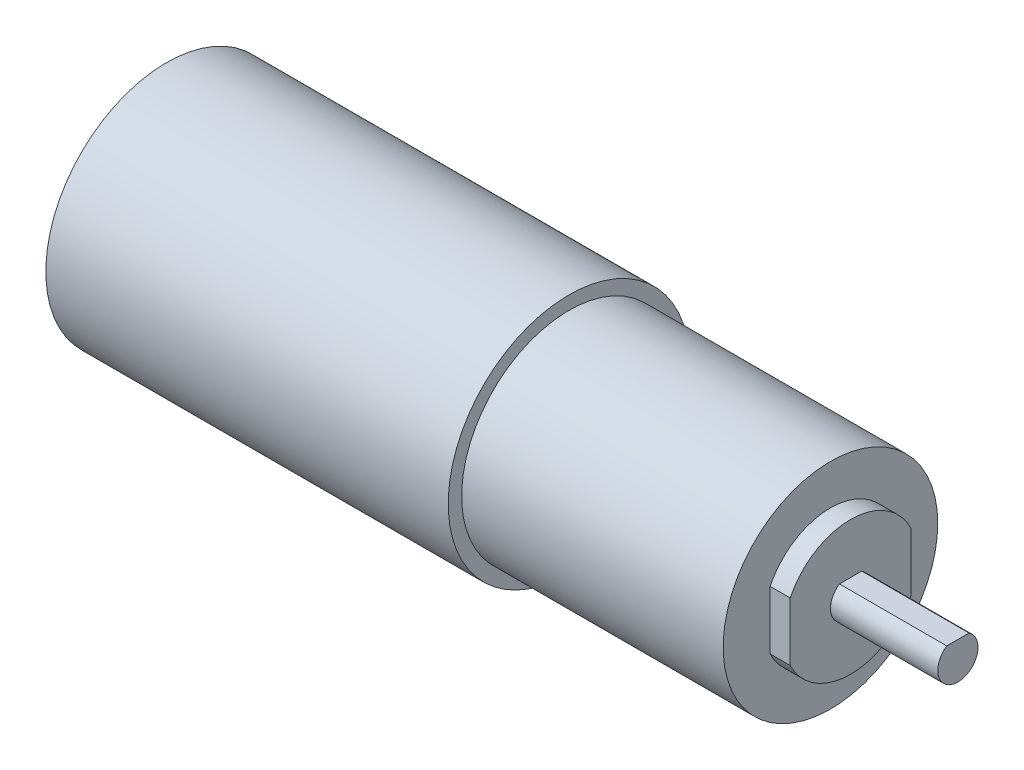
from build123d import *

# Parameters (mm, degrees)
SKETCH1_R           = 18
BOSS_EXTRUDE1_DEPTH = 60
SKETCH2_R           = 8
BOSS_EXTRUDE2_DEPTH = 3
SKETCH3_R           = 16
BOSS_EXTRUDE3_DEPTH = 39
BOSS_EXTRUDE4_DEPTH = 3
BOSS_EXTRUDE5_DEPTH = 16


with BuildPart() as part:
    # Sketch1 → Boss-Extrude1 (new body)
    with BuildSketch(Plane(origin=(0, 0, 0), x_dir=(0, 0, -1), z_dir=(1, 0, 0))):
        Circle(SKETCH1_R)
    extrude(amount=BOSS_EXTRUDE1_DEPTH)

    # Sketch2 → Boss-Extrude2 (add)
    with BuildSketch(Plane.ZY):
        Circle(SKETCH2_R)
    extrude(amount=BOSS_EXTRUDE2_DEPTH)

    # Sketch3 → Boss-Extrude3 (add)
    with BuildSketch(Plane(origin=(60, 0, 0), x_dir=(0, 0, -1), z_dir=(1, 0, 0))):
        Circle(SKETCH3_R)
    extrude(amount=BOSS_EXTRUDE3_DEPTH)

    # Sketch4 → Boss-Extrude4 (add)
    with BuildSketch(Plane(origin=(99, 0, 0), x_dir=(0, 0, -1), z_dir=(1, 0, 0))):
        with BuildLine():
            Line((9, 4.358898944), (9, -4.358898944))
            ThreePointArc((9, -4.358898944), (0, -10), (-9, -4.358898944))
            Line((-9, -4.358898944), (-9, 4.358898944))
            ThreePointArc((-9, 4.358898944), (0, 10), (9, 4.358898944))
        make_face()
    extrude(amount=BOSS_EXTRUDE4_DEPTH)

    # Sketch5 → Boss-Extrude5 (add)
    with BuildSketch(Plane(origin=(102, 0, 0), x_dir=(0, 0, -1), z_dir=(1, 0, 0))):
        with BuildLine():
            Line((-1.658312395, 2.5), (1.658312395, 2.5))
            ThreePointArc((1.658312395, 2.5), (0, -3), (-1.658312395, 2.5))
        make_face()
    extrude(amount=BOSS_EXTRUDE5_DEPTH)


solid = part.part
